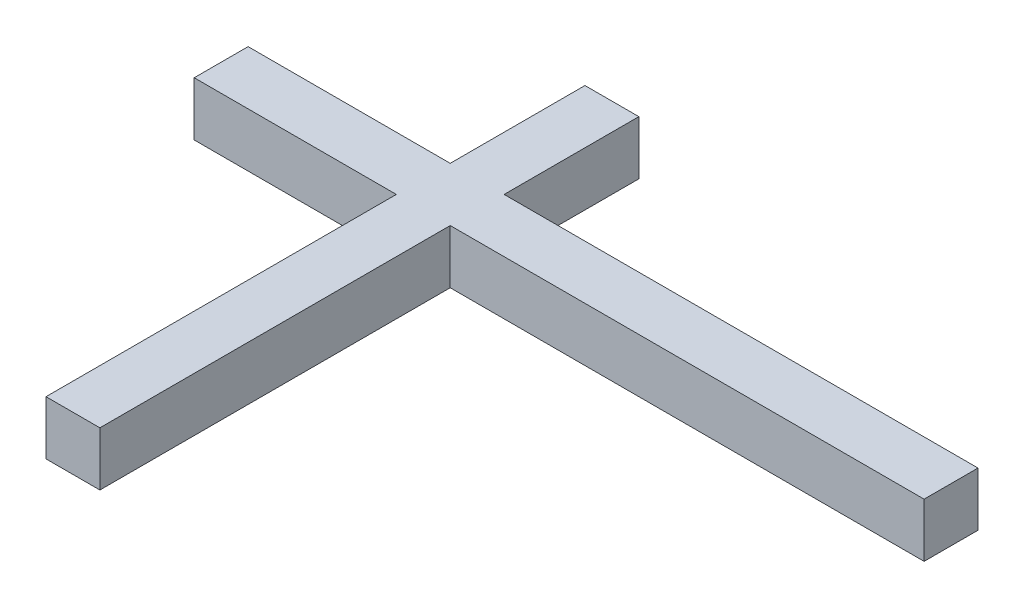
from build123d import *

# Parameters (mm, degrees)
BOSS_EXTRUDE1_DEPTH = 8


with BuildPart() as part:
    # Sketch1 → Boss-Extrude1 (new body)
    with BuildSketch(Plane(origin=(0, 0, 0), x_dir=(1, 0, 0), z_dir=(0, 1, 0))):
        Polygon((-9.362999404, -28), (-9.362999404, -80), (-1.362999404, -80), (-1.362999404, -28), (68.978559736, -28), (68.978559736, -20), (-1.362999404, -20), (-1.362999404, 0), (-9.362999404, 0), (-9.362999404, -20), (-39.362999404, -20), (-39.362999404, -28), align=None)
    extrude(amount=BOSS_EXTRUDE1_DEPTH)


solid = part.part
